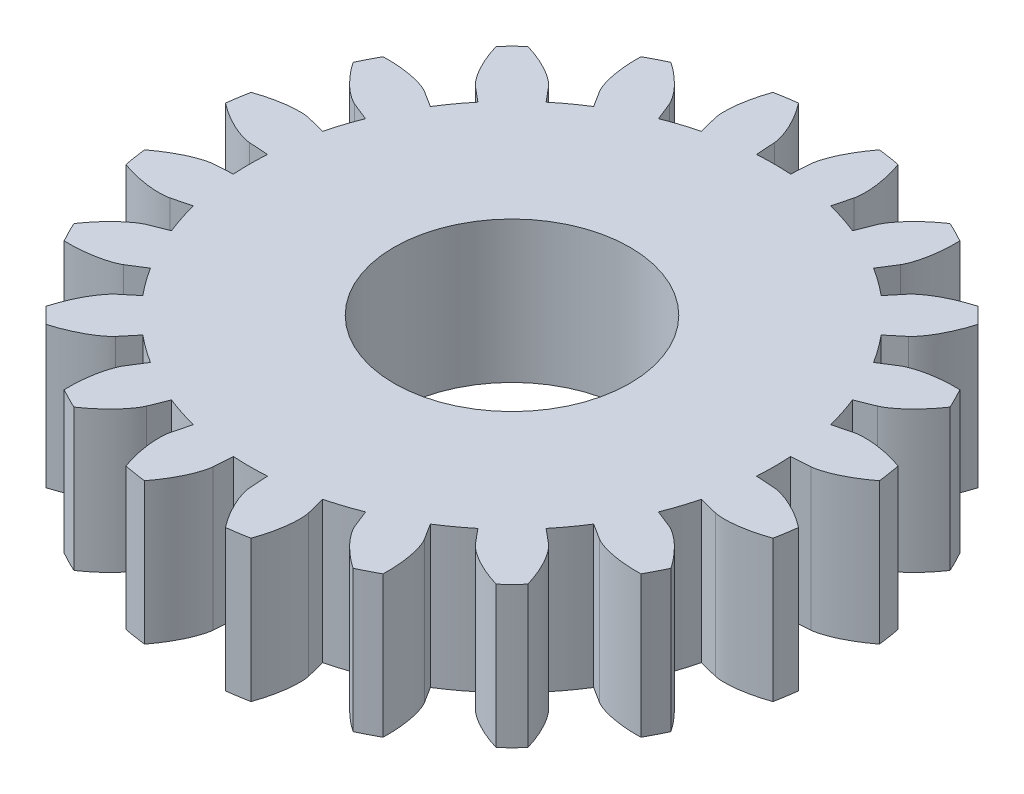
from build123d import *

# Parameters (mm, degrees)
SKETCH1_R           = 13.97
SKETCH1_R_2         = 5
BOSS_EXTRUDE1_DEPTH = 6
CUT_EXTRUDE1_START  = 6
CUT_EXTRUDE1_DEPTH  = 6
CIRPATTERN1_COUNT   = 20


with BuildPart() as part:
    # Sketch1 → Boss-Extrude1 (new body)
    with BuildSketch(Plane(origin=(0, 0, 0), x_dir=(1, 0, 0), z_dir=(0, 1, 0))):
        Circle(SKETCH1_R)
        Circle(SKETCH1_R_2, mode=Mode.SUBTRACT)
    extrude(amount=BOSS_EXTRUDE1_DEPTH)

    # Sketch1_3 → Cut-Extrude1 (cut)
    with BuildSketch(Plane(origin=(0, 0, 0), x_dir=(1, 0, 0), z_dir=(0, 1, 0)).offset(CUT_EXTRUDE1_START)):
        with BuildLine():
            Line((-0.775325429, 11.908884272), (-0.721948577, 11.089023695))
            ThreePointArc((-0.721948577, 11.089023695), (0, 11.1125), (0.721948577, 11.089023695))
            Line((0.721948577, 11.089023695), (0.775325429, 11.908884272))
            add(Edge.make_bspline(
                [(0.775325429, 11.908884272), (0.775898758, 11.917690519), (0.778083199, 11.942345293), (0.784486832, 11.988753188), (0.798146784, 12.064023679), (0.820246491, 12.159137836), (0.854155833, 12.280930336), (0.900916732, 12.422719883), (0.959367328, 12.576503324), (1.03047832, 12.741336727), (1.107992665, 12.903381168), (1.191342903, 13.06260073), (1.279755502, 13.21889384), (1.393099733, 13.40528004), (1.512531583, 13.586471165), (1.612561263, 13.727064096), (1.68883993, 13.829119389), (1.715547857, 13.864263253)],
                knots=[0, 0, 0, 0, 0, 0.005376748, 0.015083688, 0.02853182, 0.046610139, 0.064854849, 0.092110525, 0.119476175, 0.146842495, 0.174208853, 0.201574955, 0.228941013, 0.256307345, 0.307035032, 0.333940628, 0.333940628, 0.333940628, 0.333940628, 0.333940628], degree=4))
            ThreePointArc((1.715547857, 13.864263253), (0, 13.97), (-1.715547857, 13.864263253))
            add(Edge.make_bspline(
                [(-0.775325429, 11.908884272), (-0.775898758, 11.917690519), (-0.778083199, 11.942345293), (-0.784486832, 11.988753188), (-0.798146784, 12.064023679), (-0.820246491, 12.159137836), (-0.854155833, 12.280930336), (-0.900916732, 12.422719883), (-0.959367328, 12.576503324), (-1.03047832, 12.741336727), (-1.107992665, 12.903381168), (-1.191342903, 13.06260073), (-1.279755502, 13.21889384), (-1.393099733, 13.40528004), (-1.512531583, 13.586471165), (-1.612561263, 13.727064096), (-1.68883993, 13.829119389), (-1.715547857, 13.864263253)],
                knots=[0, 0, 0, 0, 0, 0.005376748, 0.015083688, 0.02853182, 0.046610139, 0.064854849, 0.092110525, 0.119476175, 0.146842495, 0.174208853, 0.201574955, 0.228941013, 0.256307345, 0.307035032, 0.333940628, 0.333940628, 0.333940628, 0.333940628, 0.333940628], degree=4))
        make_face()
    cut_extrude1 = extrude(amount=-CUT_EXTRUDE1_DEPTH, mode=Mode.SUBTRACT)

    # CirPattern1: Cut-Extrude1 ×20 about axis
    cirpattern1_axis = Axis((0, 6, 0), (0, -1, 0))
    for i in range(1, CIRPATTERN1_COUNT):
        add(cut_extrude1.rotate(cirpattern1_axis, i * 360 / CIRPATTERN1_COUNT), mode=Mode.SUBTRACT)


solid = part.part
